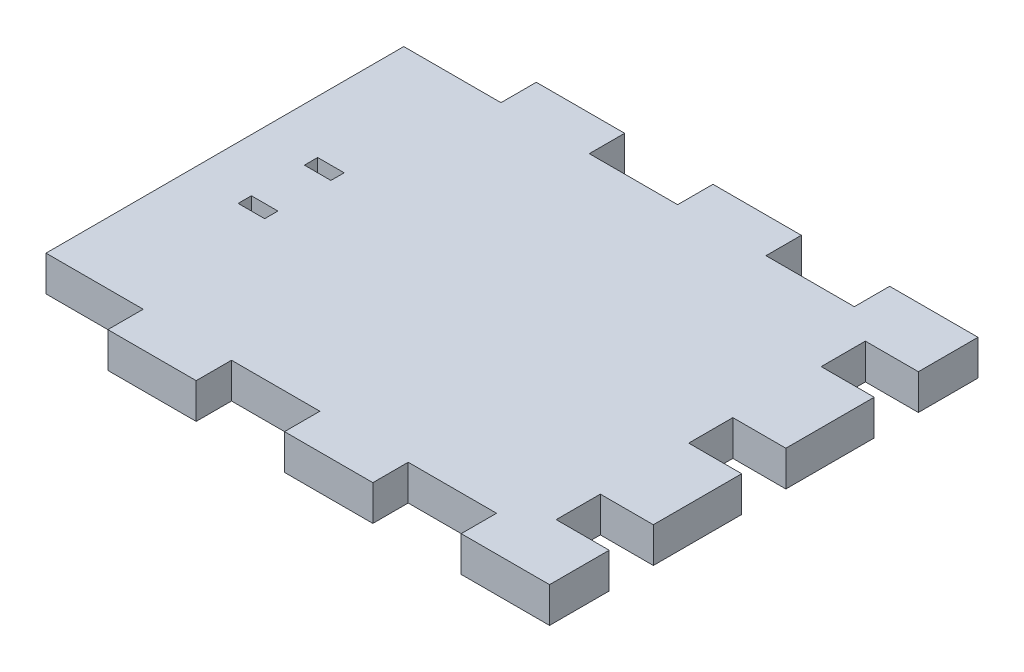
from build123d import *

# Parameters (mm, degrees)
SKETCH1_W           = 55
SKETCH1_H           = 40.5
BOSS_EXTRUDE1_DEPTH = 4
SKETCH2_W           = 2.75
SKETCH2_H           = 4
SKETCH2_W_2         = 10
BOSS_EXTRUDE2_DEPTH = 6
SKETCH3_W           = 10
SKETCH3_H           = 4
BOSS_EXTRUDE3_DEPTH = 4
LPATTERN1_COUNT     = 3
LPATTERN1_PITCH     = 20
SKETCH4_W           = 3
SKETCH4_H           = 1.5
CUT_EXTRUDE1_DEPTH  = 5


with BuildPart() as part:
    # Sketch1 → Boss-Extrude1 (new body)
    with BuildSketch(Plane(origin=(0, 0, 0), x_dir=(1, 0, 0), z_dir=(0, 1, 0))):
        with Locations((27.5, -20.25)):
            Rectangle(SKETCH1_W, SKETCH1_H)
    extrude(amount=BOSS_EXTRUDE1_DEPTH)

    # Sketch2 → Boss-Extrude2 (add)
    with BuildSketch(Plane(origin=(55, 0, 0), x_dir=(0, 0, -1), z_dir=(1, 0, 0))):
        with Locations((-39.125, 2)):
            Rectangle(SKETCH2_W, SKETCH2_H)
        with Locations((-27.75, 2)):
            Rectangle(SKETCH2_W_2, SKETCH2_H)
        with Locations((-12.75, 2)):
            Rectangle(SKETCH2_W_2, SKETCH2_H)
        with Locations((-1.375, 2)):
            Rectangle(SKETCH2_W, SKETCH2_H)
    extrude(amount=BOSS_EXTRUDE2_DEPTH)

    # Sketch3 → Boss-Extrude3 (add, through all)
    with BuildSketch(Plane(origin=(0, 4, 0), x_dir=(1, 0, 0), z_dir=(0, 1, 0))):
        with Locations((56, 2)):
            Rectangle(SKETCH3_W, SKETCH3_H)
        with Locations((56, -42.5)):
            Rectangle(SKETCH3_W, SKETCH3_H)
    boss_extrude3 = extrude(amount=-BOSS_EXTRUDE3_DEPTH)

    # LPattern1: Boss-Extrude3 ×3
    with Locations(*[(-i * LPATTERN1_PITCH, 0, 0) for i in range(1, LPATTERN1_COUNT)]):
        add(boss_extrude3)

    # Sketch4 → Cut-Extrude1 (cut, through all)
    with BuildSketch(Plane(origin=(0, 4, 0), x_dir=(1, 0, 0), z_dir=(0, 1, 0))):
        with Locations((7.5, -24)):
            Rectangle(SKETCH4_W, SKETCH4_H)
        with Locations((7.5, -16.5)):
            Rectangle(SKETCH4_W, SKETCH4_H)
    extrude(amount=-CUT_EXTRUDE1_DEPTH, mode=Mode.SUBTRACT)


solid = part.part
